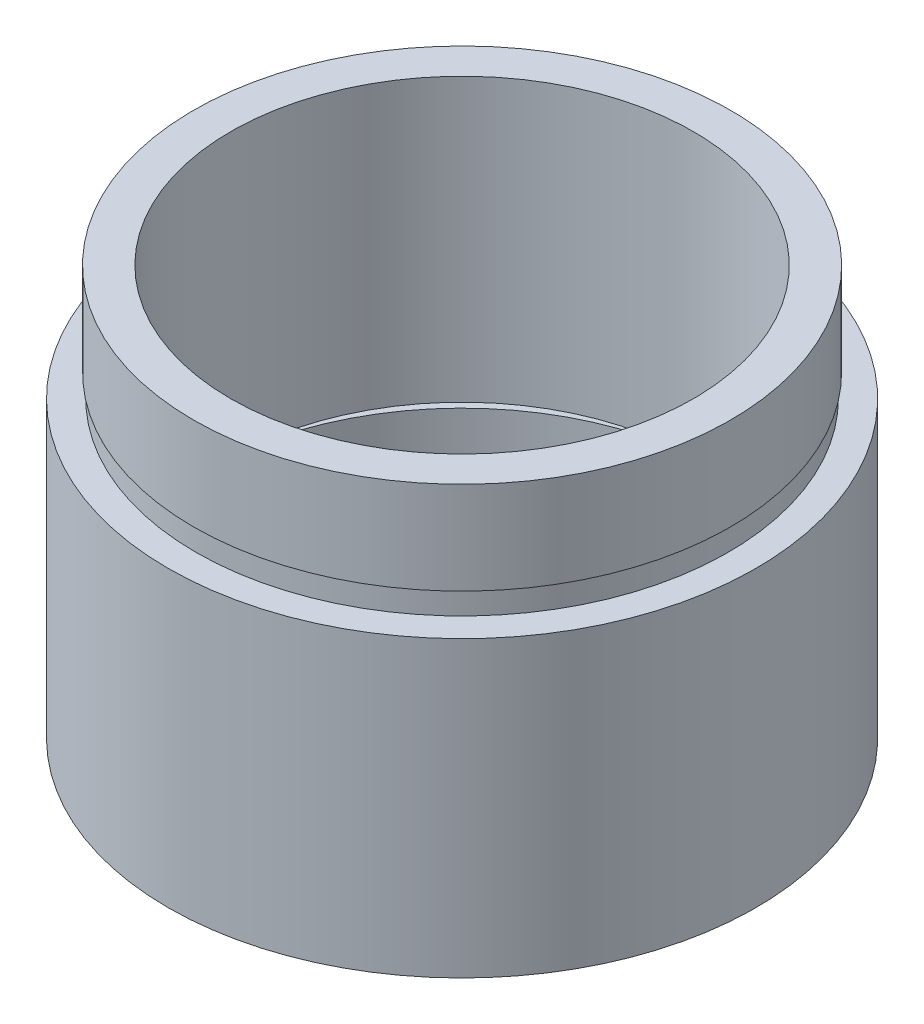
from build123d import *


with BuildPart() as part:
    # 草图1 → 旋转1 (revolve)
    with BuildSketch(Plane.XY, mode=Mode.PRIVATE) as revolve_1_sk:
        Polygon((12.7, 0), (12.7, 12.7), (11.5, 12.7), (11.5, 13.7), (11.6, 13.7), (11.6, 17.7), (10, 17.7), (10, 5.5), (11.7, 5.5), (11.7, 4.5), (11.1, 4.5), (11.1, 0), align=None)
    revolve(revolve_1_sk.sketch.rotate(Axis((0, 161.376166943, 0), (0, -1, 0)), 90), axis=Axis((0, 161.376166943, 0), (0, -1, 0)))  # turned: the seam where the file's is


solid = part.part
